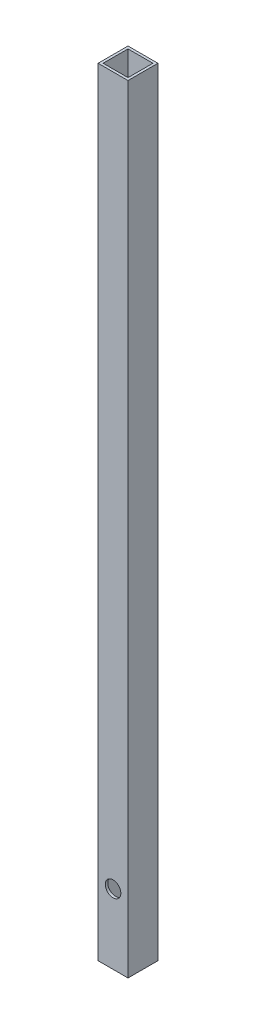
from build123d import *

# Parameters (mm, degrees)
SKETCH1_W           = 19.05
SKETCH1_H           = 19.05
SKETCH1_W_2         = 15.875
SKETCH1_H_2         = 15.875
BOSS_EXTRUDE1_DEPTH = 495.3
SKETCH2_R           = 4.9609375
CUT_EXTRUDE1_DEPTH  = 1.5875
CUT_EXTRUDE2_REACH  = 21.05
SKETCH3_R           = 0.889


with BuildPart() as part:
    # Sketch1 → Boss-Extrude1 (new body)
    with BuildSketch(Plane(origin=(0, 0, 0), x_dir=(1, 0, 0), z_dir=(0, 1, 0))):
        Rectangle(SKETCH1_W, SKETCH1_H)
        Rectangle(SKETCH1_W_2, SKETCH1_H_2, mode=Mode.SUBTRACT)
    extrude(amount=BOSS_EXTRUDE1_DEPTH)

    # Sketch2 → Cut-Extrude1 (cut)
    with BuildSketch(Plane.XY.offset(9.525)):
        with Locations((0, 44.45)):
            Circle(SKETCH2_R)
    extrude(amount=-CUT_EXTRUDE1_DEPTH, mode=Mode.SUBTRACT)

    # Sketch3 → Cut-Extrude2 (cut, up to next)
    with BuildSketch(Plane.ZY.offset(9.525), mode=Mode.PRIVATE) as cut_extrude2_sk1:
        with Locations((0, 9.525)):
            Circle(SKETCH3_R)
    cut_extrude2_tool1 = extrude(cut_extrude2_sk1.sketch, amount=-CUT_EXTRUDE2_REACH, mode=Mode.PRIVATE) & part.part
    add(cut_extrude2_tool1.solids().sort_by_distance((-9.525, 9.525, 0))[0], mode=Mode.SUBTRACT)


solid = part.part
